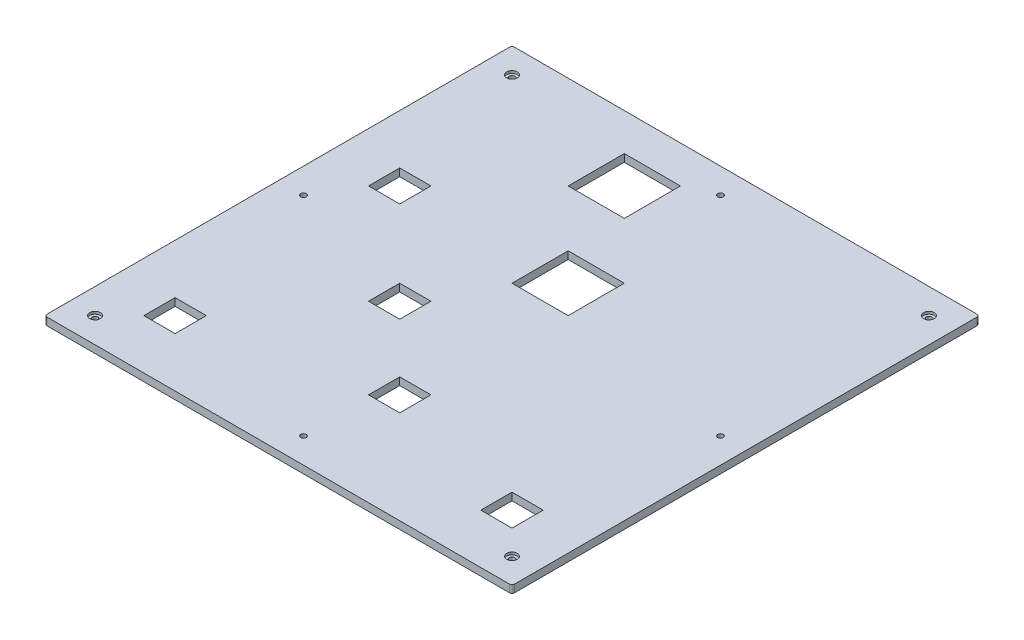
from build123d import *

# Parameters (mm, degrees)
ESQUISSE2_W             = 185
ESQUISSE2_H             = 185
BOSS_EXTRU_1_DEPTH      = 3
ESQUISSE3_W             = 185
ESQUISSE3_H             = 185
ESQUISSE3_W_2           = 155.54
ESQUISSE3_H_2           = 155.54
BOSS_EXTRU_2_DEPTH      = 40
BOSS_EXTRU_3_DEPTH      = 20
ENL_V_MAT_EXTRU_1_REACH = 5
ESQUISSE5_W             = 22.22
ESQUISSE5_H             = 22.22
ESQUISSE5_W_2           = 12.35
ESQUISSE5_H_2           = 12.35
CONG_1_R                = 1
ESQUISSE6_R             = 1.1
ENL_V_MAT_EXTRU_2_DEPTH = 44
ESQUISSE7_R             = 2.1
ENL_V_MAT_EXTRU_3_DEPTH = 41
ESQUISSE8_W             = 226.485362767
ESQUISSE8_H             = 93.740227698
ENL_V_MAT_EXTRU_4_DEPTH = 186


with BuildPart() as part:
    # Esquisse2 → Boss.-Extru.1 (new body)
    with BuildSketch(Plane(origin=(0, 0, 0), x_dir=(1, 0, 0), z_dir=(0, 1, 0))):
        Rectangle(ESQUISSE2_W, ESQUISSE2_H)
    extrude(amount=-BOSS_EXTRU_1_DEPTH)

    # Esquisse3 → Boss.-Extru.2 (add)
    with BuildSketch(Plane(origin=(0, 0, 0), x_dir=(1, 0, 0), z_dir=(0, 1, 0))):
        Rectangle(ESQUISSE3_W, ESQUISSE3_H)
        Rectangle(ESQUISSE3_W_2, ESQUISSE3_H_2, mode=Mode.SUBTRACT)
    extrude(amount=BOSS_EXTRU_2_DEPTH)

    # Esquisse4 → Boss.-Extru.3 (add)
    with BuildSketch(Plane(origin=(0, 0, 0), x_dir=(1, 0, 0), z_dir=(0, 1, 0))):
        Polygon((-55.55, 77.77), (-33.33, 77.77), (-33.33, 55.55), (11.11, 55.55), (11.11, 33.33), (-11.11, 33.33), (-11.11, -11.11), (-33.33, -11.11), (-33.33, -55.55), (-55.55, -55.55), (-55.55, 11.11), (-33.33, 11.11), (-33.33, 33.33), (-55.55, 33.33), align=None)
        Polygon((33.33, 55.55), (55.55, 55.55), (55.55, -55.55), (33.33, -55.55), (33.33, -77.77), (11.11, -77.77), (11.11, -33.33), (33.33, -33.33), align=None)
    extrude(amount=BOSS_EXTRU_3_DEPTH)

    # Esquisse5 → Enlèv. mat.-Extru.1 (cut, up to next)
    with BuildSketch(Plane(origin=(0, 0, 0), x_dir=(1, 0, 0), z_dir=(0, 1, 0)), mode=Mode.PRIVATE) as enl_v_mat_extru_1_sk1:
        with Locations((-22.22, 66.66)):
            Rectangle(ESQUISSE5_W, ESQUISSE5_H)
    enl_v_mat_extru_1_tool1 = extrude(enl_v_mat_extru_1_sk1.sketch, amount=-ENL_V_MAT_EXTRU_1_REACH, mode=Mode.PRIVATE) & part.part
    add(enl_v_mat_extru_1_tool1.solids().sort_by_distance((-22.22, 0, -66.66))[0], mode=Mode.SUBTRACT)
    # Esquisse5 → Enlèv. mat.-Extru.1 (cut, up to next)
    with BuildSketch(Plane(origin=(0, 0, 0), x_dir=(1, 0, 0), z_dir=(0, 1, 0)), mode=Mode.PRIVATE) as enl_v_mat_extru_1_sk2:
        with Locations((0, 22.22)):
            Rectangle(ESQUISSE5_W, ESQUISSE5_H)
    enl_v_mat_extru_1_tool2 = extrude(enl_v_mat_extru_1_sk2.sketch, amount=-ENL_V_MAT_EXTRU_1_REACH, mode=Mode.PRIVATE) & part.part
    add(enl_v_mat_extru_1_tool2.solids().sort_by_distance((0, 0, -22.22))[0], mode=Mode.SUBTRACT)
    # Esquisse5 → Enlèv. mat.-Extru.1 (cut, up to next)
    with BuildSketch(Plane(origin=(0, 0, 0), x_dir=(1, 0, 0), z_dir=(0, 1, 0)), mode=Mode.PRIVATE) as enl_v_mat_extru_1_sk3:
        with Locations((-27.155, -17.285)):
            Rectangle(ESQUISSE5_W_2, ESQUISSE5_H_2)
    enl_v_mat_extru_1_tool3 = extrude(enl_v_mat_extru_1_sk3.sketch, amount=-ENL_V_MAT_EXTRU_1_REACH, mode=Mode.PRIVATE) & part.part
    add(enl_v_mat_extru_1_tool3.solids().sort_by_distance((-27.155, 0, 17.285))[0], mode=Mode.SUBTRACT)
    # Esquisse5 → Enlèv. mat.-Extru.1 (cut, up to next)
    with BuildSketch(Plane(origin=(0, 0, 0), x_dir=(1, 0, 0), z_dir=(0, 1, 0)), mode=Mode.PRIVATE) as enl_v_mat_extru_1_sk4:
        with Locations((-66.66, 22.22)):
            Rectangle(ESQUISSE5_W_2, ESQUISSE5_H_2)
    enl_v_mat_extru_1_tool4 = extrude(enl_v_mat_extru_1_sk4.sketch, amount=-ENL_V_MAT_EXTRU_1_REACH, mode=Mode.PRIVATE) & part.part
    add(enl_v_mat_extru_1_tool4.solids().sort_by_distance((-66.66, 0, -22.22))[0], mode=Mode.SUBTRACT)
    # Esquisse5 → Enlèv. mat.-Extru.1 (cut, up to next)
    with BuildSketch(Plane(origin=(0, 0, 0), x_dir=(1, 0, 0), z_dir=(0, 1, 0)), mode=Mode.PRIVATE) as enl_v_mat_extru_1_sk5:
        with Locations((-66.66, -66.66)):
            Rectangle(ESQUISSE5_W_2, ESQUISSE5_H_2)
    enl_v_mat_extru_1_tool5 = extrude(enl_v_mat_extru_1_sk5.sketch, amount=-ENL_V_MAT_EXTRU_1_REACH, mode=Mode.PRIVATE) & part.part
    add(enl_v_mat_extru_1_tool5.solids().sort_by_distance((-66.66, 0, 66.66))[0], mode=Mode.SUBTRACT)
    # Esquisse5 → Enlèv. mat.-Extru.1 (cut, up to next)
    with BuildSketch(Plane(origin=(0, 0, 0), x_dir=(1, 0, 0), z_dir=(0, 1, 0)), mode=Mode.PRIVATE) as enl_v_mat_extru_1_sk6:
        with Locations((66.66, -66.66)):
            Rectangle(ESQUISSE5_W_2, ESQUISSE5_H_2)
    enl_v_mat_extru_1_tool6 = extrude(enl_v_mat_extru_1_sk6.sketch, amount=-ENL_V_MAT_EXTRU_1_REACH, mode=Mode.PRIVATE) & part.part
    add(enl_v_mat_extru_1_tool6.solids().sort_by_distance((66.66, 0, 66.66))[0], mode=Mode.SUBTRACT)
    # Esquisse5 → Enlèv. mat.-Extru.1 (cut, up to next)
    with BuildSketch(Plane(origin=(0, 0, 0), x_dir=(1, 0, 0), z_dir=(0, 1, 0)), mode=Mode.PRIVATE) as enl_v_mat_extru_1_sk7:
        with Locations((4.935, -49.375)):
            Rectangle(ESQUISSE5_W_2, ESQUISSE5_H_2)
    enl_v_mat_extru_1_tool7 = extrude(enl_v_mat_extru_1_sk7.sketch, amount=-ENL_V_MAT_EXTRU_1_REACH, mode=Mode.PRIVATE) & part.part
    add(enl_v_mat_extru_1_tool7.solids().sort_by_distance((4.935, 0, 49.375))[0], mode=Mode.SUBTRACT)

    # Congé1
    cong_1_edges = [part.edges().sort_by_distance(p)[0] for p in [
        (-92.5, 40, 0),
        (0, 40, 92.5),
        (92.5, 40, 0),
        (0, 40, -92.5),
        (-92.5, 18.5, -92.5),
        (92.5, 18.5, -92.5),
        (92.5, 18.5, 92.5),
        (-92.5, 18.5, 92.5),
    ]]
    fillet(cong_1_edges, radius=CONG_1_R)

    # Esquisse6 → Enlèv. mat.-Extru.2 (cut, through all)
    with BuildSketch(Plane(origin=(0, 40, 0), x_dir=(1, 0, 0), z_dir=(0, 1, 0))):
        with Locations(Location((-82.5, -82.5, 0), (0, 0, 270))):  # turned: the seam where the file's is
            Circle(ESQUISSE6_R)
        with Locations(Location((82.5, -82.5, 0), (0, 0, 270))):  # turned: the seam where the file's is
            Circle(ESQUISSE6_R)
        with Locations(Location((82.5, 82.5, 0), (0, 0, 270))):  # turned: the seam where the file's is
            Circle(ESQUISSE6_R)
        with Locations(Location((-82.5, 82.5, 0), (0, 0, 270))):  # turned: the seam where the file's is
            Circle(ESQUISSE6_R)
        with Locations(Location((0, 82.5, 0), (0, 0, 270))):  # turned: the seam where the file's is
            Circle(ESQUISSE6_R)
        with Locations(Location((-82.5, 0, 0), (0, 0, 270))):  # turned: the seam where the file's is
            Circle(ESQUISSE6_R)
        with Locations(Location((82.5, 0, 0), (0, 0, 270))):  # turned: the seam where the file's is
            Circle(ESQUISSE6_R)
        with Locations(Location((0, -82.5, 0), (0, 0, 270))):  # turned: the seam where the file's is
            Circle(ESQUISSE6_R)
    extrude(amount=-ENL_V_MAT_EXTRU_2_DEPTH, mode=Mode.SUBTRACT)

    # Esquisse7 → Enlèv. mat.-Extru.3 (cut)
    with BuildSketch(Plane(origin=(0, 40, 0), x_dir=(1, 0, 0), z_dir=(0, 1, 0))):
        with Locations(Location((-82.5, -82.5, 0), (0, 0, 270))):  # turned: the seam where the file's is
            Circle(ESQUISSE7_R)
        with Locations(Location((-82.5, 82.5, 0), (0, 0, 270))):  # turned: the seam where the file's is
            Circle(ESQUISSE7_R)
        with Locations(Location((82.5, 82.5, 0), (0, 0, 270))):  # turned: the seam where the file's is
            Circle(ESQUISSE7_R)
        with Locations(Location((82.5, -82.5, 0), (0, 0, 270))):  # turned: the seam where the file's is
            Circle(ESQUISSE7_R)
    extrude(amount=-ENL_V_MAT_EXTRU_3_DEPTH, mode=Mode.SUBTRACT)

    # Esquisse8 → Enlèv. mat.-Extru.4 (cut, through all)
    with BuildSketch(Plane.XY.offset(92.5)):
        with Locations((0.829347629, 46.870113849)):
            Rectangle(ESQUISSE8_W, ESQUISSE8_H)
    extrude(amount=-ENL_V_MAT_EXTRU_4_DEPTH, mode=Mode.SUBTRACT)


solid = part.part
